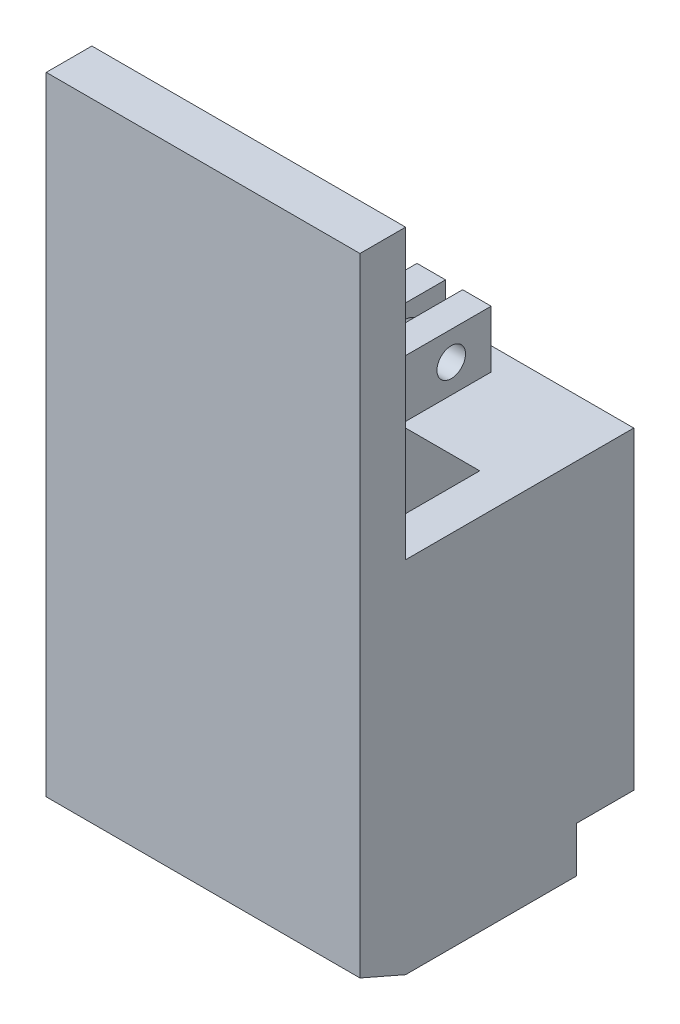
from build123d import *

# Parameters (mm, degrees)
BOSS_EXTRUDE1_DEPTH  = 40
CUT_EXTRUDE1_REACH   = 80.602
SKETCH2_R            = 2.5
CUT_EXTRUDE2_DEPTH   = 10
SKETCH6_W            = 55
SKETCH6_H            = 110
BOSS_EXTRUDE8_DEPTH  = 8
CUT_EXTRUDE3_REACH   = 117.156
SKETCH7_W            = 4
SKETCH7_H            = 10
BOSS_EXTRUDE9_DEPTH  = 20
BOSS_EXTRUDE10_START = -48
BOSS_EXTRUDE10_DEPTH = 7
RIB1_REACH           = 120.495
SKETCH10_WALL_W      = 267.27372249
SKETCH10_WALL_H      = 8


with BuildPart() as part:
    # Sketch1 → Boss-Extrude1 (new body)
    with BuildSketch(Plane.XY):
        Polygon((-21, 0), (21, 0), (21, 42), (1.5, 42), (1.5, 58.5), (6.5, 58.5), (6.5, 48.5), (27.5, 48.5), (27.5, -6.5), (-27.5, -6.5), (-27.5, 48.5), (-6.5, 48.5), (-6.5, 58.5), (-1.5, 58.5), (-1.5, 42), (-21, 42), align=None)
    extrude(amount=BOSS_EXTRUDE1_DEPTH)

    # Cut-Extrude1: up to this face of the body (flat: up to its plane)
    cut_extrude1_end = Plane(part.part.faces().sort_by_distance((6.5, 53.5, 20))[0])
    # Sketch2 → Cut-Extrude1 (cut, up to the picked face)
    with BuildSketch(Plane.ZY.offset(6.5), mode=Mode.PRIVATE) as cut_extrude1_sk1:
        with Locations(Location((11, 53.5, 0), (0, 0, 270))):
            Circle(SKETCH2_R)
    cut_extrude1_tool1 = split(extrude(cut_extrude1_sk1.sketch, amount=-CUT_EXTRUDE1_REACH, mode=Mode.PRIVATE), bisect_by=cut_extrude1_end, keep=Keep.BOTH, mode=Mode.PRIVATE)
    # Sketch2 → Cut-Extrude1 (cut, up to the picked face)
    with BuildSketch(Plane.ZY.offset(6.5), mode=Mode.PRIVATE) as cut_extrude1_sk2:
        with Locations(Location((29, 53.5, 0), (0, 0, 270))):
            Circle(SKETCH2_R)
    cut_extrude1_tool2 = split(extrude(cut_extrude1_sk2.sketch, amount=-CUT_EXTRUDE1_REACH, mode=Mode.PRIVATE), bisect_by=cut_extrude1_end, keep=Keep.BOTH, mode=Mode.PRIVATE)
    add(cut_extrude1_tool1.solids().sort_by(Axis((-6.5, 53.5, 11), (1, 0, 0)))[0], mode=Mode.SUBTRACT)
    add(cut_extrude1_tool2.solids().sort_by(Axis((-6.5, 53.5, 29), (1, 0, 0)))[0], mode=Mode.SUBTRACT)

    # Sketch3 → Cut-Extrude2 (cut)
    with BuildSketch(Plane(origin=(0, 0, 0), x_dir=(-1, 0, 0), z_dir=(0, 0, -1))):
        with BuildLine():
            Line((20.5, -6.5), (19.170549473, -5.005824209))
            ThreePointArc((19.170549473, -5.005824209), (18.157592064, -4.262982703), (16.929285786, -4))
            Line((16.929285786, -4), (-3.929285786, -4))
            ThreePointArc((-3.929285786, -4), (-5.157592064, -4.262982703), (-6.170549473, -5.005824209))
            Line((-6.170549473, -5.005824209), (-7.5, -6.5))
            Line((-7.5, -6.5), (20.5, -6.5))
        make_face()
    extrude(amount=-CUT_EXTRUDE2_DEPTH, mode=Mode.SUBTRACT)

    # Cut-Extrude3: up to this face of the body (flat: up to its plane)
    cut_extrude3_end = Plane(part.part.faces().sort_by_distance((6.5, 53.5, 20))[0])
    # Sketch7 → Cut-Extrude3 (cut, up to the picked face)
    with BuildSketch(Plane.ZY.offset(6.5), mode=Mode.PRIVATE) as cut_extrude3_sk1:
        with Locations((38, 53.5)):
            Rectangle(SKETCH7_W, SKETCH7_H)
    cut_extrude3_tool1 = split(extrude(cut_extrude3_sk1.sketch, amount=-CUT_EXTRUDE3_REACH, mode=Mode.PRIVATE), bisect_by=cut_extrude3_end, keep=Keep.BOTH, mode=Mode.PRIVATE)
    # Sketch7 → Cut-Extrude3 (cut, up to the picked face)
    with BuildSketch(Plane.ZY.offset(6.5), mode=Mode.PRIVATE) as cut_extrude3_sk2:
        with Locations((2, 53.5)):
            Rectangle(SKETCH7_W, SKETCH7_H)
    cut_extrude3_tool2 = split(extrude(cut_extrude3_sk2.sketch, amount=-CUT_EXTRUDE3_REACH, mode=Mode.PRIVATE), bisect_by=cut_extrude3_end, keep=Keep.BOTH, mode=Mode.PRIVATE)
    add(cut_extrude3_tool1.solids().sort_by(Axis((-6.5, 53.5, 38), (1, 0, 0)))[0], mode=Mode.SUBTRACT)
    add(cut_extrude3_tool2.solids().sort_by(Axis((-6.5, 53.5, 2), (1, 0, 0)))[0], mode=Mode.SUBTRACT)



with BuildPart() as body_2:
    # Sketch6 → Boss-Extrude8 (new body)
    with BuildSketch(Plane.XY.offset(40)):
        with Locations((0, 44)):
            Rectangle(SKETCH6_W, SKETCH6_H)
    extrude(amount=BOSS_EXTRUDE8_DEPTH)


with BuildPart() as part_1:
    add(part.part)

    add(body_2.part)  # Boss-Extrude9 merges body 2
    # Sketch9 → Boss-Extrude9 (add)
    with BuildSketch(Plane(origin=(27.5, 0, 0), x_dir=(0, 0, -1), z_dir=(1, 0, 0))):
        Polygon((-40, -14.5), (-48, -11), (-40, -11), (-40, -6.5), (-10, -6.5), (-10, -14.5), align=None)
    extrude(amount=-BOSS_EXTRUDE9_DEPTH)

    # Sketch9_2 → Boss-Extrude10 (add)
    with BuildSketch(Plane(origin=(27.5, 0, 0), x_dir=(0, 0, -1), z_dir=(1, 0, 0)).offset(BOSS_EXTRUDE10_START)):
        Polygon((-40, -14.5), (-48, -11), (-40, -11), (-40, -6.5), (-10, -6.5), (-10, -14.5), align=None)
    extrude(amount=-BOSS_EXTRUDE10_DEPTH)

    # Sketch10 wall → Rib1 (add, up to next)
    with BuildSketch(Plane(origin=(16.5, 58.5, 30), x_dir=(0, -0.707106781187, -0.707106781187), z_dir=(0, 0.707106781187, -0.707106781187)), mode=Mode.PRIVATE) as rib1_sk1:
        Rectangle(SKETCH10_WALL_W, SKETCH10_WALL_H)
    rib1_tool1 = extrude(rib1_sk1.sketch, amount=-RIB1_REACH, mode=Mode.PRIVATE) - part_1.part
    rib1 = rib1_tool1.solids().sort_by_distance((16.5, 58.5, 30))[0]
    add(rib1)

    # Mirror1: Rib1 across plane
    add(rib1.mirror(Plane(origin=(0, 0, 0), x_dir=(0, 0, 1), z_dir=(1, 0, 0))))


solid = part_1.part
